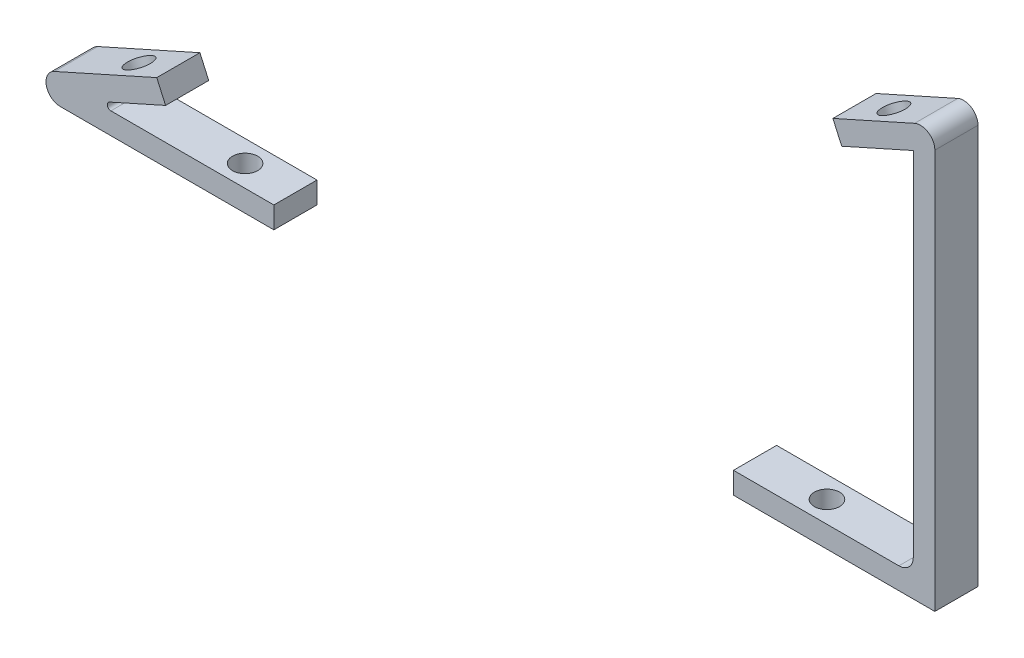
from build123d import *

# Parameters (mm, degrees)
BOSS_EXTRUDE1_DEPTH   = 6
BOSS_EXTRUDE1_2_DEPTH = 6
FILLET1_R             = 2
FILLET2_R             = 2
FILLET3_R             = 2
FILLET4_R             = 0.5
SKETCH2_R             = 1.75
CUT_EXTRUDE1_DEPTH    = 3
SKETCH3_R             = 1.75
CUT_EXTRUDE2_DEPTH    = 3


with BuildPart() as part:
    # Sketch1 → Boss-Extrude1 (new body)
    with BuildSketch(Plane.XY):
        Polygon((-25, 0), (0, 0), (0, -3), (-25, -3), (-39.040980861, -3), (-16.279249839, 7.191819861), (-15.053255633, 4.453766135), (-20.529363085, 2.001777723), align=None)
    extrude(amount=BOSS_EXTRUDE1_DEPTH)

    # Fillet1
    fillet1_edges = [part.edges().sort_by_distance(p)[0] for p in [
        (-39.040980861, -3, 3),
    ]]
    fillet(fillet1_edges, radius=FILLET1_R)

    # Fillet4
    fillet4_edges = [part.edges().sort_by_distance(p)[0] for p in [
        (-25, 0, 3),
    ]]
    fillet(fillet4_edges, radius=FILLET4_R)


with BuildPart() as body_2:
    # Sketch1 → Boss-Extrude1 2 (new body)
    with BuildSketch(Plane.XY):
        Polygon((88.9, 0), (88.9, 51), (84.429363085, 48.998222277), (78.953255633, 46.546233865), (77.727261427, 49.284287592), (83.203368879, 51.736276003), (91.9, 55.630289938), (91.9, 51), (91.9, -3), (63.9, -3), (63.9, 0), align=None)
    extrude(amount=BOSS_EXTRUDE1_2_DEPTH)

    # Fillet2
    fillet2_edges = [body_2.edges().sort_by_distance(p)[0] for p in [
        (91.9, 55.630289938, 3),
    ]]
    fillet(fillet2_edges, radius=FILLET2_R)

    # Fillet3
    fillet3_edges = [body_2.edges().sort_by_distance(p)[0] for p in [
        (88.9, 0, 3),
    ]]
    fillet(fillet3_edges, radius=FILLET3_R)


with BuildPart() as cut_extrude1_tool:
    # Sketch2 → Cut-Extrude1 (new body)
    with BuildSketch(Plane(origin=(-5.401165852, 12.062603735, 0), x_dir=(0.912684575, 0.408664735, 0), z_dir=(-0.408664735, 0.912684575, 0))):
        with Locations((97.081222933, -3)):
            Circle(SKETCH2_R)
        with Locations((-17.918777067, -3)):
            Circle(SKETCH2_R)
    extrude(amount=-CUT_EXTRUDE1_DEPTH)


with BuildPart() as part_1:
    add(part.part)

    # Cut-Extrude1: cut by cut_extrude1_tool
    add(cut_extrude1_tool.part, mode=Mode.SUBTRACT)


with BuildPart() as body_2_1:
    add(body_2.part)

    # Cut-Extrude1: cut by cut_extrude1_tool
    add(cut_extrude1_tool.part, mode=Mode.SUBTRACT)


with BuildPart() as cut_extrude2_tool:
    # Sketch3 → Cut-Extrude2 (new body)
    with BuildSketch(Plane(origin=(0, 0, 0), x_dir=(1, 0, 0), z_dir=(0, 1, 0))):
        with Locations((73.9, -3)):
            Circle(SKETCH3_R)
        with Locations((-7, -3)):
            Circle(SKETCH3_R)
    extrude(amount=-CUT_EXTRUDE2_DEPTH)


with BuildPart() as part_2:
    add(part_1.part)

    # Cut-Extrude2: cut by cut_extrude2_tool
    add(cut_extrude2_tool.part, mode=Mode.SUBTRACT)


with BuildPart() as body_2_2:
    add(body_2_1.part)

    # Cut-Extrude2: cut by cut_extrude2_tool
    add(cut_extrude2_tool.part, mode=Mode.SUBTRACT)


solid = Compound([part_2.part, body_2_2.part])
